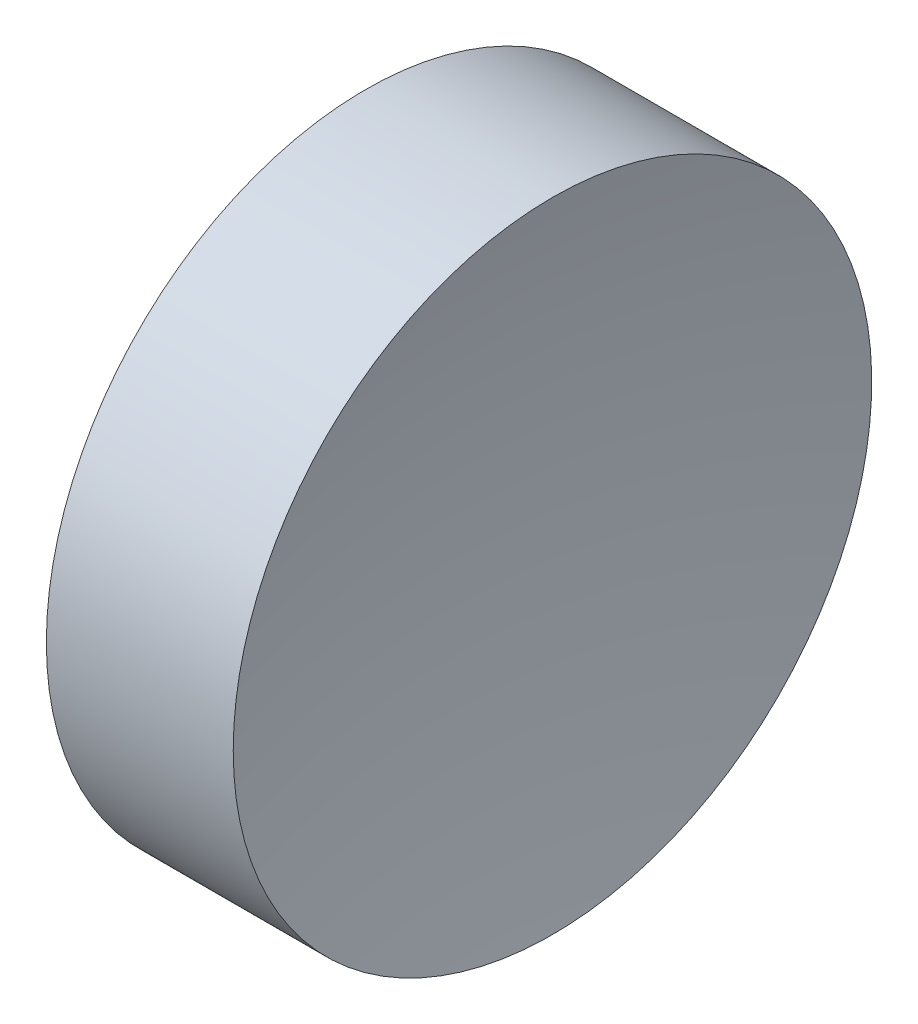
from build123d import *


with BuildPart() as part:
    # 草图1 → 旋转1 (revolve)
    with BuildSketch(Plane.XY):
        with BuildLine():
            Line((57.546327767, 34.689010562), (57.546327767, 40.939010562))
            Line((57.546327767, 40.939010562), (61.204591282, 40.939010562))
            ThreePointArc((61.204591282, 40.939010562), (60.711347505, 37.831295194), (60.546327767, 34.689010562))
            Line((60.546327767, 34.689010562), (57.546327767, 34.689010562))
        make_face()
    revolve(axis=Axis((54.492571501, 34.689010562, 0), (1, 0, 0)))


solid = part.part
